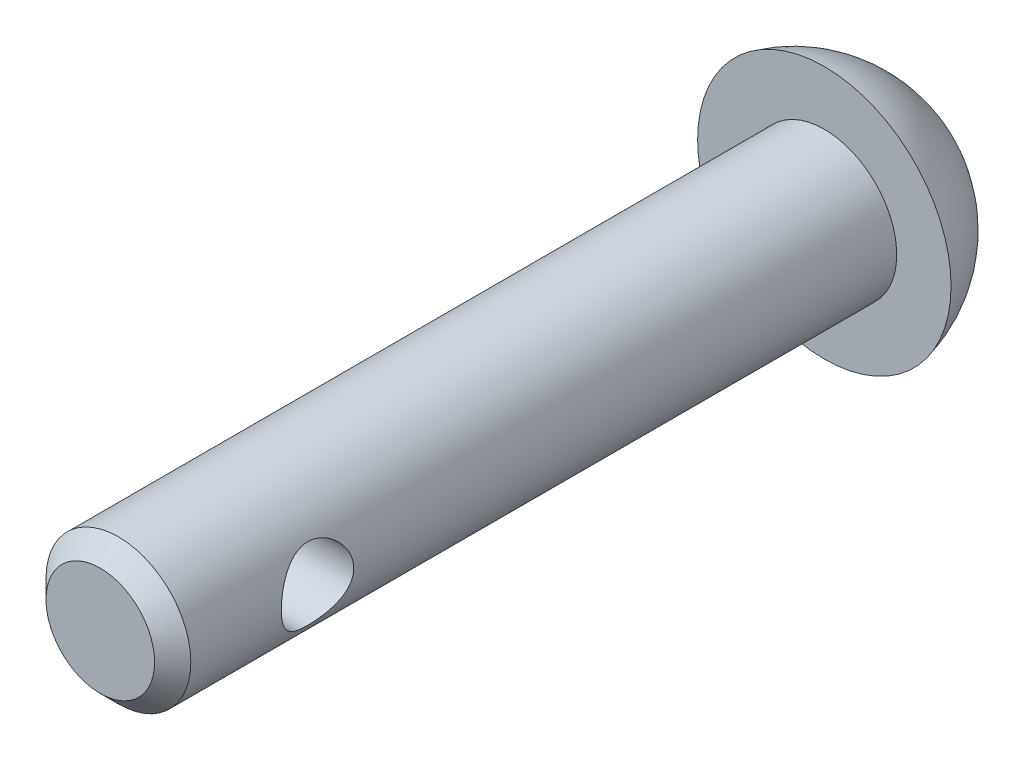
from build123d import *

# Parameters (mm, degrees)
SKETCH2_R           = 2
BOSS_EXTRUDE1_DEPTH = 10
CHAMFER1_SIZE       = 0.5
SKETCH4_R           = 1
CUT_EXTRUDE1_DEPTH  = 10


with BuildPart() as part:
    # Sketch2 → Boss-Extrude1 (new body, symmetric)
    with BuildSketch(Plane.XY):
        Circle(SKETCH2_R)
    extrude(amount=BOSS_EXTRUDE1_DEPTH, both=True)

    # Chamfer1
    chamfer1_edges = [part.edges().sort_by_distance(p)[0] for p in [
        (-2, 0, 10),
    ]]
    chamfer(chamfer1_edges, length=CHAMFER1_SIZE)

    # Sketch3 → Revolve1 (revolve)
    with BuildSketch(Plane(origin=(0, 0, 0), x_dir=(0, 0, -1), z_dir=(1, 0, 0))):
        with BuildLine():
            Line((10, 0), (10, 3.5))
            ThreePointArc((10, 3.5), (11.985229955, 2.227844932), (12.757385023, 0))
            Line((12.757385023, 0), (10, 0))
        make_face()
    revolve(axis=Axis((0, 0, -6.005295168), (0, 0, -1)))

    # Sketch4 → Cut-Extrude1 (cut, symmetric)
    with BuildSketch(Plane(origin=(0, 0, 0), x_dir=(0, 0, -1), z_dir=(1, 0, 0))):
        with Locations((-6, 0)):
            Circle(SKETCH4_R)
    extrude(amount=CUT_EXTRUDE1_DEPTH, both=True, mode=Mode.SUBTRACT)


solid = part.part
